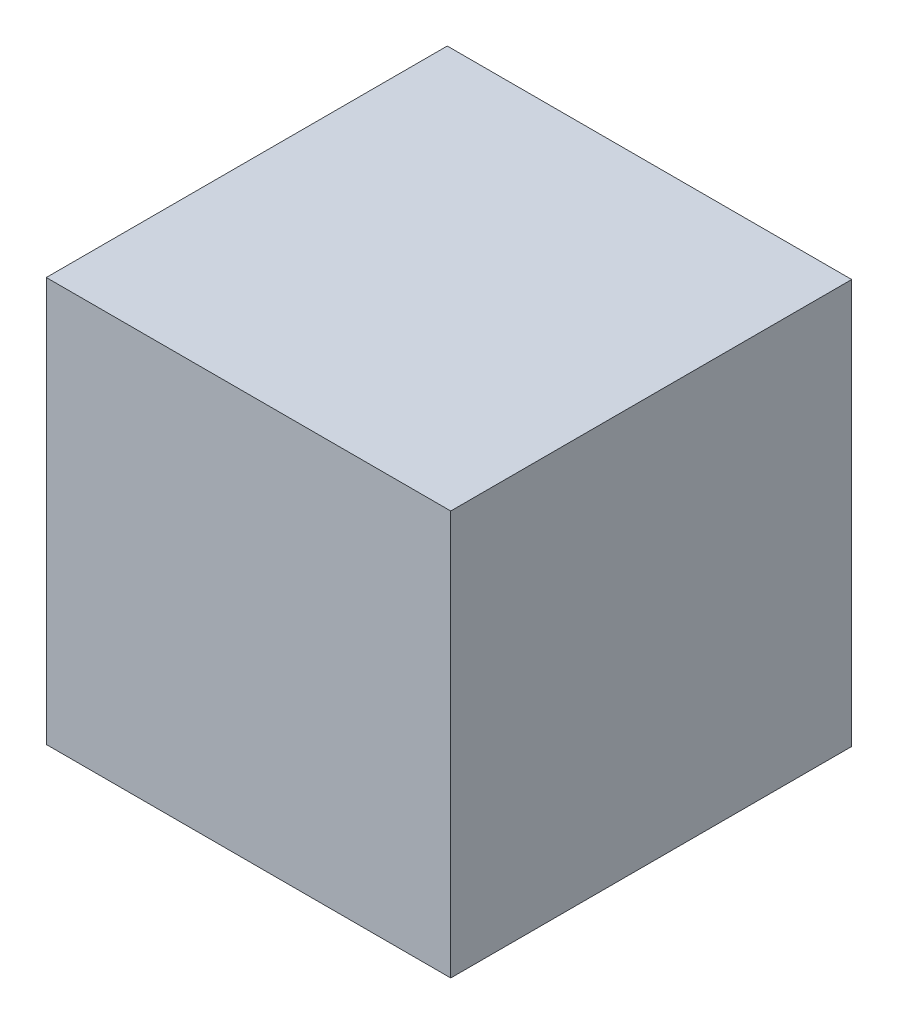
from build123d import *

# Parameters (mm, degrees)
ESQUISSE1_W        = 116
ESQUISSE1_H        = 116
BOSS_EXTRU_1_DEPTH = 115


with BuildPart() as part:
    # Esquisse1 → Boss.-Extru.1 (new body)
    with BuildSketch(Plane.XY):
        with Locations((-8.282939914, -6.422746781)):
            Rectangle(ESQUISSE1_W, ESQUISSE1_H)
    extrude(amount=BOSS_EXTRU_1_DEPTH)


solid = part.part
